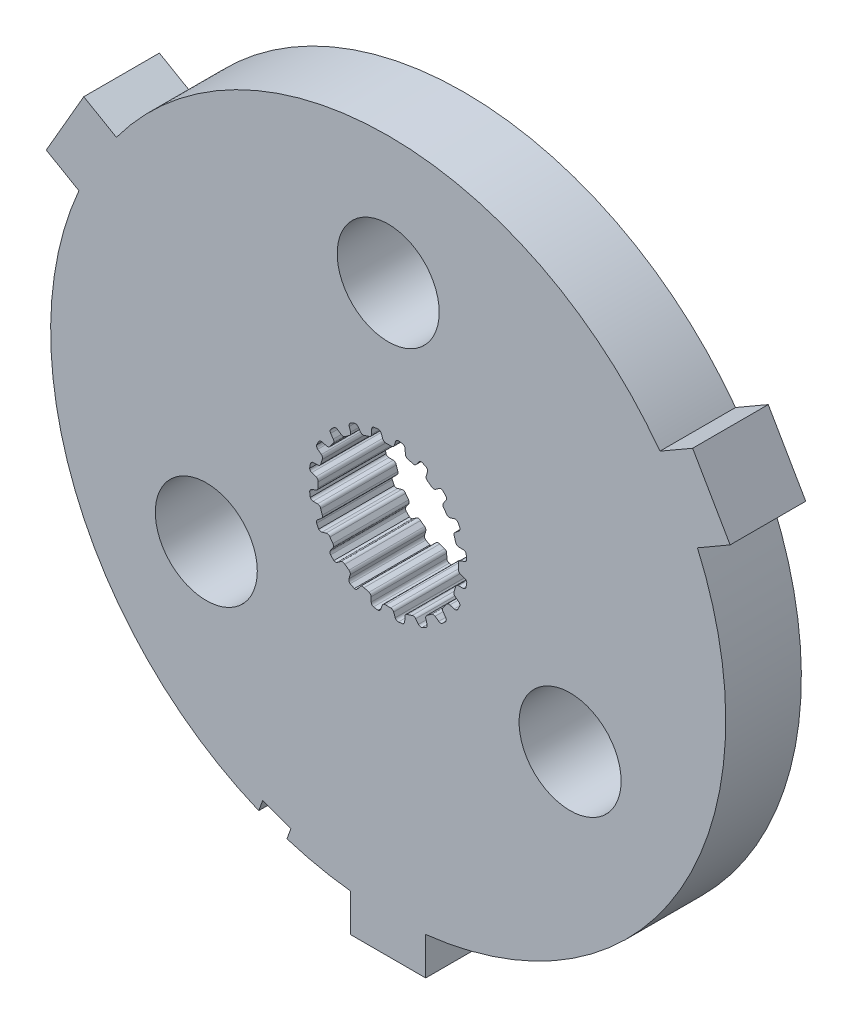
from build123d import *

# Parameters (mm, degrees)
SKETCH1_R           = 14.2875
BOSS_EXTRUDE1_DEPTH = 3.2004
SKETCH5_R           = 2.159
CUT_EXTRUDE2_DEPTH  = 3.2004
SKETCH6_R           = 2.159
SKETCH6_R_2         = 5.927061266
BOSS_EXTRUDE2_DEPTH = 3.2004
CUT_EXTRUDE3_DEPTH  = 3.2004


with BuildPart() as part:
    # Sketch1 → Boss-Extrude1 (new body)
    with BuildSketch(Plane.XY):
        Circle(SKETCH1_R)
        with BuildLine():
            Line((-0.106949245, 2.969874934), (0.106949245, 2.969874934))
            ThreePointArc((0.106949245, 2.969874934), (0.196343213, 2.986924176), (0.253739238, 3.057547504))
            Line((0.253739238, 3.057547504), (0.315888147, 3.237526941))
            ThreePointArc((0.315888147, 3.237526941), (0.359032156, 3.298322911), (0.4281449, 3.326269005))
            Line((0.4281449, 3.326269005), (0.620027588, 3.2937547))
            ThreePointArc((0.620027588, 3.2937547), (0.689621142, 3.24802576), (0.718272212, 3.169836791))
            Line((0.718272212, 3.169836791), (0.724389167, 2.979527391))
            ThreePointArc((0.724389167, 2.979527391), (0.750934762, 2.9040661), (0.816027049, 2.857568043))
            Line((0.816027049, 2.857568043), (1.019456602, 2.791469774))
            ThreePointArc((1.019456602, 2.791469774), (1.109743823, 2.780060312), (1.186154496, 2.829490741))
            Line((1.186154496, 2.829490741), (1.300878326, 2.981456288))
            ThreePointArc((1.300878326, 2.981456288), (1.360697704, 3.02594446), (1.435063648, 3.031165762))
            Line((1.435063648, 3.031165762), (1.607507455, 2.940947809))
            ThreePointArc((1.607507455, 2.940947809), (1.659563839, 2.875951412), (1.662650905, 2.792735615))
            Line((1.662650905, 2.792735615), (1.609659636, 2.609850378))
            ThreePointArc((1.609659636, 2.609850378), (1.611587176, 2.529879385), (1.659124931, 2.465542482))
            Line((1.659124931, 2.465542482), (1.832172444, 2.339816104))
            ThreePointArc((1.832172444, 2.339816104), (1.914514976, 2.301064775), (2.002460687, 2.32446371))
            Line((2.002460687, 2.32446371), (2.158529469, 2.433539921))
            ThreePointArc((2.158529469, 2.433539921), (2.229168681, 2.457365482), (2.301508367, 2.439350895))
            Line((2.301508367, 2.439350895), (2.437633293, 2.300260456))
            ThreePointArc((2.437633293, 2.300260456), (2.467056864, 2.222358901), (2.444277744, 2.14226202))
            Line((2.444277744, 2.14226202), (2.337365406, 1.984703026))
            ThreePointArc((2.337365406, 1.984703026), (2.314486209, 1.908050449), (2.339816104, 1.832172444))
            Line((2.339816104, 1.832172444), (2.465542482, 1.659124931))
            ThreePointArc((2.465542482, 1.659124931), (2.531880064, 1.596824985), (2.622752074, 1.591901975))
            Line((2.622752074, 1.591901975), (2.804888709, 1.64741171))
            ThreePointArc((2.804888709, 1.64741171), (2.879433095, 1.648242449), (2.942665411, 1.608755366))
            Line((2.942665411, 1.608755366), (3.0291466, 1.434407582))
            ThreePointArc((3.0291466, 1.434407582), (3.033057175, 1.351226417), (2.986641646, 1.282088892))
            Line((2.986641646, 1.282088892), (2.836273564, 1.165279113))
            ThreePointArc((2.836273564, 1.165279113), (2.790827206, 1.099448241), (2.791469774, 1.019456602))
            Line((2.791469774, 1.019456602), (2.857568043, 0.816027049))
            ThreePointArc((2.857568043, 0.816027049), (2.901407091, 0.736276839), (2.986310214, 0.703513784))
            Line((2.986310214, 0.703513784), (3.1766859, 0.700023363))
            ThreePointArc((3.1766859, 0.700023363), (3.247838536, 0.677777961), (3.295773863, 0.620683653))
            Line((3.295773863, 0.620683653), (3.324145932, 0.4281449))
            ThreePointArc((3.324145932, 0.4281449), (3.302160717, 0.347826477), (3.236652255, 0.29641597))
            Line((3.236652255, 0.29641597), (3.057547504, 0.231789562))
            ThreePointArc((3.057547504, 0.231789562), (2.993982591, 0.183224379), (2.969874934, 0.106949245))
            Line((2.969874934, 0.106949245), (2.969874934, -0.106949245))
            ThreePointArc((2.969874934, -0.106949245), (2.986924176, -0.196343213), (3.057547504, -0.253739238))
            Line((3.057547504, -0.253739238), (3.237526941, -0.315888147))
            ThreePointArc((3.237526941, -0.315888147), (3.298322911, -0.359032156), (3.326269005, -0.4281449))
            Line((3.326269005, -0.4281449), (3.2937547, -0.620027588))
            ThreePointArc((3.2937547, -0.620027588), (3.24802576, -0.689621142), (3.169836791, -0.718272212))
            Line((3.169836791, -0.718272212), (2.979527391, -0.724389167))
            ThreePointArc((2.979527391, -0.724389167), (2.9040661, -0.750934762), (2.857568043, -0.816027049))
            Line((2.857568043, -0.816027049), (2.791469774, -1.019456602))
            ThreePointArc((2.791469774, -1.019456602), (2.780060312, -1.109743823), (2.829490741, -1.186154496))
            Line((2.829490741, -1.186154496), (2.981456288, -1.300878326))
            ThreePointArc((2.981456288, -1.300878326), (3.02594446, -1.360697704), (3.031165762, -1.435063648))
            Line((3.031165762, -1.435063648), (2.940947809, -1.607507455))
            ThreePointArc((2.940947809, -1.607507455), (2.875951412, -1.659563839), (2.792735615, -1.662650905))
            Line((2.792735615, -1.662650905), (2.609850378, -1.609659636))
            ThreePointArc((2.609850378, -1.609659636), (2.529879385, -1.611587176), (2.465542482, -1.659124931))
            Line((2.465542482, -1.659124931), (2.339816104, -1.832172444))
            ThreePointArc((2.339816104, -1.832172444), (2.301064775, -1.914514976), (2.32446371, -2.002460687))
            Line((2.32446371, -2.002460687), (2.433539921, -2.158529469))
            ThreePointArc((2.433539921, -2.158529469), (2.457365482, -2.229168681), (2.439350895, -2.301508367))
            Line((2.439350895, -2.301508367), (2.300260456, -2.437633293))
            ThreePointArc((2.300260456, -2.437633293), (2.222358901, -2.467056864), (2.14226202, -2.444277744))
            Line((2.14226202, -2.444277744), (1.984703026, -2.337365406))
            ThreePointArc((1.984703026, -2.337365406), (1.908050449, -2.314486209), (1.832172444, -2.339816104))
            Line((1.832172444, -2.339816104), (1.659124931, -2.465542482))
            ThreePointArc((1.659124931, -2.465542482), (1.596824985, -2.531880064), (1.591901975, -2.622752074))
            Line((1.591901975, -2.622752074), (1.64741171, -2.804888709))
            ThreePointArc((1.64741171, -2.804888709), (1.648242449, -2.879433095), (1.608755366, -2.942665411))
            Line((1.608755366, -2.942665411), (1.434407582, -3.0291466))
            ThreePointArc((1.434407582, -3.0291466), (1.351226417, -3.033057175), (1.282088892, -2.986641646))
            Line((1.282088892, -2.986641646), (1.165279113, -2.836273564))
            ThreePointArc((1.165279113, -2.836273564), (1.099448241, -2.790827206), (1.019456602, -2.791469774))
            Line((1.019456602, -2.791469774), (0.816027049, -2.857568043))
            ThreePointArc((0.816027049, -2.857568043), (0.736276839, -2.901407091), (0.703513784, -2.986310214))
            Line((0.703513784, -2.986310214), (0.700023363, -3.1766859))
            ThreePointArc((0.700023363, -3.1766859), (0.677777961, -3.247838536), (0.620683653, -3.295773863))
            Line((0.620683653, -3.295773863), (0.4281449, -3.324145932))
            ThreePointArc((0.4281449, -3.324145932), (0.347826477, -3.302160717), (0.29641597, -3.236652255))
            Line((0.29641597, -3.236652255), (0.231789562, -3.057547504))
            ThreePointArc((0.231789562, -3.057547504), (0.183224379, -2.993982591), (0.106949245, -2.969874934))
            Line((0.106949245, -2.969874934), (-0.106949245, -2.969874934))
            ThreePointArc((-0.106949245, -2.969874934), (-0.196343213, -2.986924176), (-0.253739238, -3.057547504))
            Line((-0.253739238, -3.057547504), (-0.315888147, -3.237526941))
            ThreePointArc((-0.315888147, -3.237526941), (-0.359032156, -3.298322911), (-0.4281449, -3.326269005))
            Line((-0.4281449, -3.326269005), (-0.620027588, -3.2937547))
            ThreePointArc((-0.620027588, -3.2937547), (-0.689621142, -3.24802576), (-0.718272212, -3.169836791))
            Line((-0.718272212, -3.169836791), (-0.724389167, -2.979527391))
            ThreePointArc((-0.724389167, -2.979527391), (-0.750934762, -2.9040661), (-0.816027049, -2.857568043))
            Line((-0.816027049, -2.857568043), (-1.019456602, -2.791469774))
            ThreePointArc((-1.019456602, -2.791469774), (-1.109743823, -2.780060312), (-1.186154496, -2.829490741))
            Line((-1.186154496, -2.829490741), (-1.300878326, -2.981456288))
            ThreePointArc((-1.300878326, -2.981456288), (-1.360697704, -3.02594446), (-1.435063648, -3.031165762))
            Line((-1.435063648, -3.031165762), (-1.607507455, -2.940947809))
            ThreePointArc((-1.607507455, -2.940947809), (-1.659563839, -2.875951412), (-1.662650905, -2.792735615))
            Line((-1.662650905, -2.792735615), (-1.609659636, -2.609850378))
            ThreePointArc((-1.609659636, -2.609850378), (-1.611587176, -2.529879385), (-1.659124931, -2.465542482))
            Line((-1.659124931, -2.465542482), (-1.832172444, -2.339816104))
            ThreePointArc((-1.832172444, -2.339816104), (-1.914514976, -2.301064775), (-2.002460687, -2.32446371))
            Line((-2.002460687, -2.32446371), (-2.158529469, -2.433539921))
            ThreePointArc((-2.158529469, -2.433539921), (-2.229168681, -2.457365482), (-2.301508367, -2.439350895))
            Line((-2.301508367, -2.439350895), (-2.437633293, -2.300260456))
            ThreePointArc((-2.437633293, -2.300260456), (-2.467056864, -2.222358901), (-2.444277744, -2.14226202))
            Line((-2.444277744, -2.14226202), (-2.337365406, -1.984703026))
            ThreePointArc((-2.337365406, -1.984703026), (-2.314486209, -1.908050449), (-2.339816104, -1.832172444))
            Line((-2.339816104, -1.832172444), (-2.465542482, -1.659124931))
            ThreePointArc((-2.465542482, -1.659124931), (-2.531880064, -1.596824985), (-2.622752074, -1.591901975))
            Line((-2.622752074, -1.591901975), (-2.804888709, -1.64741171))
            ThreePointArc((-2.804888709, -1.64741171), (-2.879433095, -1.648242449), (-2.942665411, -1.608755366))
            Line((-2.942665411, -1.608755366), (-3.0291466, -1.434407582))
            ThreePointArc((-3.0291466, -1.434407582), (-3.033057175, -1.351226417), (-2.986641646, -1.282088892))
            Line((-2.986641646, -1.282088892), (-2.836273564, -1.165279113))
            ThreePointArc((-2.836273564, -1.165279113), (-2.790827206, -1.099448241), (-2.791469774, -1.019456602))
            Line((-2.791469774, -1.019456602), (-2.857568043, -0.816027049))
            ThreePointArc((-2.857568043, -0.816027049), (-2.901407091, -0.736276839), (-2.986310214, -0.703513784))
            Line((-2.986310214, -0.703513784), (-3.1766859, -0.700023363))
            ThreePointArc((-3.1766859, -0.700023363), (-3.247838536, -0.677777961), (-3.295773863, -0.620683653))
            Line((-3.295773863, -0.620683653), (-3.324145932, -0.4281449))
            ThreePointArc((-3.324145932, -0.4281449), (-3.302160717, -0.347826477), (-3.236652255, -0.29641597))
            Line((-3.236652255, -0.29641597), (-3.057547504, -0.231789562))
            ThreePointArc((-3.057547504, -0.231789562), (-2.993982591, -0.183224379), (-2.969874934, -0.106949245))
            Line((-2.969874934, -0.106949245), (-2.969874934, 0.106949245))
            ThreePointArc((-2.969874934, 0.106949245), (-2.986924176, 0.196343213), (-3.057547504, 0.253739238))
            Line((-3.057547504, 0.253739238), (-3.237526941, 0.315888147))
            ThreePointArc((-3.237526941, 0.315888147), (-3.298322911, 0.359032156), (-3.326269005, 0.4281449))
            Line((-3.326269005, 0.4281449), (-3.2937547, 0.620027588))
            ThreePointArc((-3.2937547, 0.620027588), (-3.24802576, 0.689621142), (-3.169836791, 0.718272212))
            Line((-3.169836791, 0.718272212), (-2.979527391, 0.724389167))
            ThreePointArc((-2.979527391, 0.724389167), (-2.9040661, 0.750934762), (-2.857568043, 0.816027049))
            Line((-2.857568043, 0.816027049), (-2.791469774, 1.019456602))
            ThreePointArc((-2.791469774, 1.019456602), (-2.780060312, 1.109743823), (-2.829490741, 1.186154496))
            Line((-2.829490741, 1.186154496), (-2.981456288, 1.300878326))
            ThreePointArc((-2.981456288, 1.300878326), (-3.02594446, 1.360697704), (-3.031165762, 1.435063648))
            Line((-3.031165762, 1.435063648), (-2.940947809, 1.607507455))
            ThreePointArc((-2.940947809, 1.607507455), (-2.875951412, 1.659563839), (-2.792735615, 1.662650905))
            Line((-2.792735615, 1.662650905), (-2.609850378, 1.609659636))
            ThreePointArc((-2.609850378, 1.609659636), (-2.529879385, 1.611587176), (-2.465542482, 1.659124931))
            Line((-2.465542482, 1.659124931), (-2.339816104, 1.832172444))
            ThreePointArc((-2.339816104, 1.832172444), (-2.301064775, 1.914514976), (-2.32446371, 2.002460687))
            Line((-2.32446371, 2.002460687), (-2.433539921, 2.158529469))
            ThreePointArc((-2.433539921, 2.158529469), (-2.457365482, 2.229168681), (-2.439350895, 2.301508367))
            Line((-2.439350895, 2.301508367), (-2.300260456, 2.437633293))
            ThreePointArc((-2.300260456, 2.437633293), (-2.222358901, 2.467056864), (-2.14226202, 2.444277744))
            Line((-2.14226202, 2.444277744), (-1.984703026, 2.337365406))
            ThreePointArc((-1.984703026, 2.337365406), (-1.908050449, 2.314486209), (-1.832172444, 2.339816104))
            Line((-1.832172444, 2.339816104), (-1.659124931, 2.465542482))
            ThreePointArc((-1.659124931, 2.465542482), (-1.596824985, 2.531880064), (-1.591901975, 2.622752074))
            Line((-1.591901975, 2.622752074), (-1.64741171, 2.804888709))
            ThreePointArc((-1.64741171, 2.804888709), (-1.648242449, 2.879433095), (-1.608755366, 2.942665411))
            Line((-1.608755366, 2.942665411), (-1.434407582, 3.0291466))
            ThreePointArc((-1.434407582, 3.0291466), (-1.351226417, 3.033057175), (-1.282088892, 2.986641646))
            Line((-1.282088892, 2.986641646), (-1.165279113, 2.836273564))
            ThreePointArc((-1.165279113, 2.836273564), (-1.099448241, 2.790827206), (-1.019456602, 2.791469774))
            Line((-1.019456602, 2.791469774), (-0.816027049, 2.857568043))
            ThreePointArc((-0.816027049, 2.857568043), (-0.736276839, 2.901407091), (-0.703513784, 2.986310214))
            Line((-0.703513784, 2.986310214), (-0.700023363, 3.1766859))
            ThreePointArc((-0.700023363, 3.1766859), (-0.677777961, 3.247838536), (-0.620683653, 3.295773863))
            Line((-0.620683653, 3.295773863), (-0.4281449, 3.324145932))
            ThreePointArc((-0.4281449, 3.324145932), (-0.347826477, 3.302160717), (-0.29641597, 3.236652255))
            Line((-0.29641597, 3.236652255), (-0.231789562, 3.057547504))
            ThreePointArc((-0.231789562, 3.057547504), (-0.183224379, 2.993982591), (-0.106949245, 2.969874934))
        make_face(mode=Mode.SUBTRACT)
    extrude(amount=BOSS_EXTRUDE1_DEPTH)

    # Sketch5 → Cut-Extrude2 (cut)
    with BuildSketch(Plane.XY.offset(3.2004)):
        with Locations((0, 8.89)):
            Circle(SKETCH5_R)
        with Locations((7.69896584, -4.445)):
            Circle(SKETCH5_R)
        with Locations((-7.69896584, -4.445)):
            Circle(SKETCH5_R)
    extrude(amount=-CUT_EXTRUDE2_DEPTH, mode=Mode.SUBTRACT)

    # Sketch6 → Boss-Extrude2 (add)
    with BuildSketch(Plane.XY.offset(3.2004)):
        with BuildLine():
            Line((1.5875, -15.795425564), (-1.5875, -15.795425564))
            Line((-1.5875, -15.795425564), (-1.5875, -14.199031657))
            ThreePointArc((-1.5875, -14.199031657), (-12.373337957, -7.14375), (-13.090472124, 5.7247005))
            Line((-13.090472124, 5.7247005), (-14.472989802, 6.522897454))
            Line((-14.472989802, 6.522897454), (-12.885489802, 9.272528111))
            Line((-12.885489802, 9.272528111), (-11.502972124, 8.474331157))
            ThreePointArc((-11.502972124, 8.474331157), (0, 14.2875), (11.502972124, 8.474331157))
            Line((11.502972124, 8.474331157), (12.885489802, 9.272528111))
            Line((12.885489802, 9.272528111), (14.472989802, 6.522897454))
            Line((14.472989802, 6.522897454), (13.090472124, 5.7247005))
            ThreePointArc((13.090472124, 5.7247005), (12.373337957, -7.14375), (1.5875, -14.199031657))
            Line((1.5875, -14.199031657), (1.5875, -15.795425564))
        make_face()
        with Locations((7.69896584, -4.445)):
            Circle(SKETCH6_R, mode=Mode.SUBTRACT)
        with Locations((-7.69896584, -4.445)):
            Circle(SKETCH6_R, mode=Mode.SUBTRACT)
        with Locations((0, 8.89)):
            Circle(SKETCH6_R, mode=Mode.SUBTRACT)
        Circle(SKETCH6_R_2, mode=Mode.SUBTRACT)
    extrude(amount=-BOSS_EXTRUDE2_DEPTH)

    # Sketch7 → Cut-Extrude3 (cut)
    with BuildSketch(Plane.XY.offset(3.2004)):
        Polygon((-4.289907984, -13.64304111), (-4.116161751, -13.165677259), (-5.309571379, -12.731311677), (-5.483317612, -13.208675528), align=None)
    extrude(amount=-CUT_EXTRUDE3_DEPTH, mode=Mode.SUBTRACT)


solid = part.part
